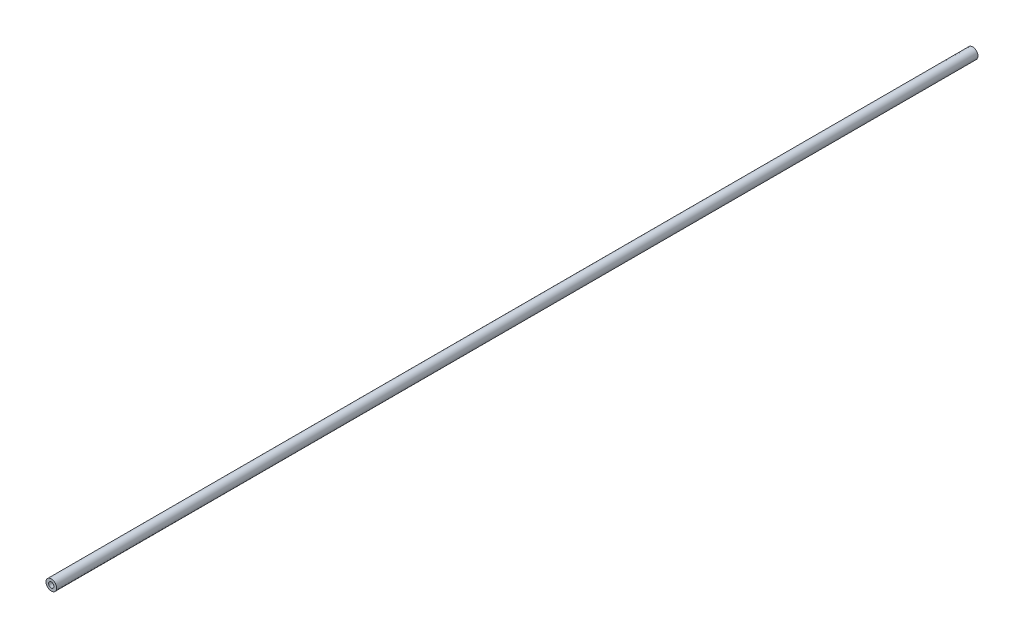
from build123d import *

# Parameters (mm, degrees)
SKETCH2_R           = 2.54
SKETCH2_R_2         = 1.27
BOSS_EXTRUDE1_DEPTH = 441.96


with BuildPart() as part:
    # Sketch2 → Boss-Extrude1 (new body)
    with BuildSketch(Plane.XY):
        Circle(SKETCH2_R)
        Circle(SKETCH2_R_2, mode=Mode.SUBTRACT)
    extrude(amount=BOSS_EXTRUDE1_DEPTH)


solid = part.part
